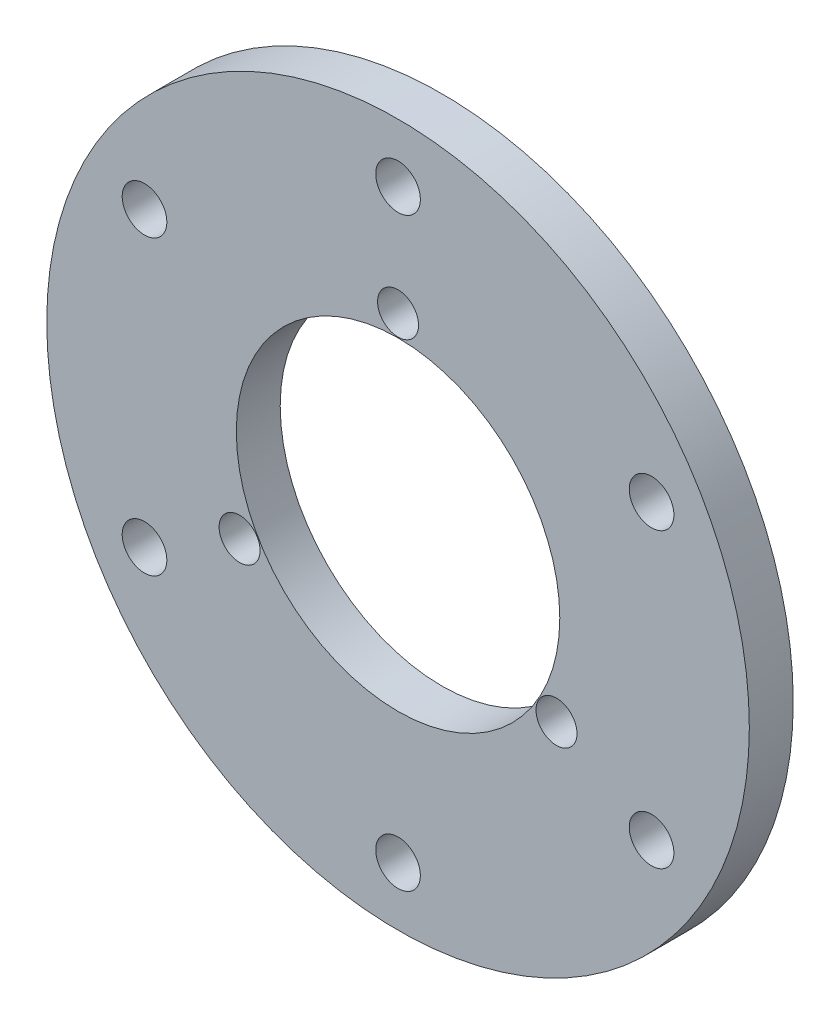
from build123d import *

# Parameters (mm, degrees)
SKETCH_1_R      = 24
SKETCH_1_R_2    = 11.05
SKETCH_1_R_3    = 1.525
SKETCH_1_R_4    = 1.4
EXTRUDE_1_DEPTH = 3


with BuildPart() as part:
    # 草图1 → 凸台-拉伸1 (new body)
    with BuildSketch(Plane.XY):
        Circle(SKETCH_1_R)
        Circle(SKETCH_1_R_2, mode=Mode.SUBTRACT)
        with Locations((0, 20)):
            Circle(SKETCH_1_R_3, mode=Mode.SUBTRACT)
        with Locations((17.320508076, 10)):
            Circle(SKETCH_1_R_3, mode=Mode.SUBTRACT)
        with Locations((17.320508076, -10)):
            Circle(SKETCH_1_R_3, mode=Mode.SUBTRACT)
        with Locations((0, -20)):
            Circle(SKETCH_1_R_3, mode=Mode.SUBTRACT)
        with Locations((-17.320508076, -10)):
            Circle(SKETCH_1_R_3, mode=Mode.SUBTRACT)
        with Locations((-17.320508076, 10)):
            Circle(SKETCH_1_R_3, mode=Mode.SUBTRACT)
        with Locations((0, 12.5)):
            Circle(SKETCH_1_R_4, mode=Mode.SUBTRACT)
        with Locations((10.825317547, -6.25)):
            Circle(SKETCH_1_R_4, mode=Mode.SUBTRACT)
        with Locations((-10.825317547, -6.25)):
            Circle(SKETCH_1_R_4, mode=Mode.SUBTRACT)
    extrude(amount=EXTRUDE_1_DEPTH)


solid = part.part
